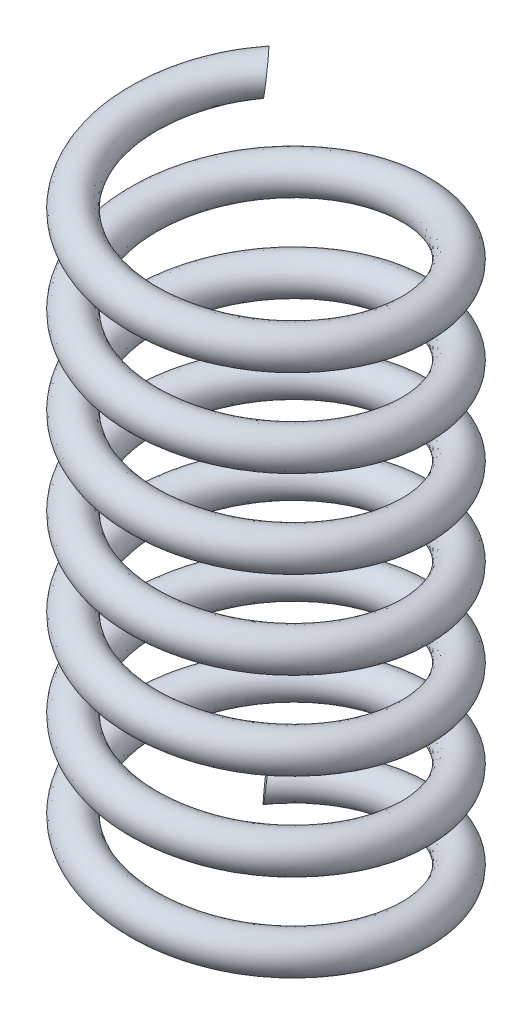
from build123d import *

# Parameters (mm, degrees)
SWEEP1_PITCH       = 1.487714286
SWEEP1_HEIGHT      = 10.414
SWEEP1_RADIUS      = 2.3241
SWEEP1_START_ANGLE = -135
SKETCH2_R          = 0.3175


with BuildPart() as part:
    # Sweep1: sweep along a helix
    with BuildLine() as sweep1_path:
        add(Helix(SWEEP1_PITCH, SWEEP1_HEIGHT, SWEEP1_RADIUS, center=(0, 0, 0), direction=(0, 1, 0), lefthand=True, mode=Mode.PRIVATE).rotate(Axis((0, 0, 0), (0, 1, 0)), SWEEP1_START_ANGLE))
    # Sketch2 → Sweep1 (sweep)
    with BuildSketch(Plane(origin=(-1.64338687, 10.414, -1.64338687), x_dir=(-0.696310209, -0.100078792, -0.710729434), z_dir=(0.703465452, 0.101354404, -0.703465452))):
        with Locations((-4.547345281, -1.219185237)):
            Circle(SKETCH2_R)
    sweep(path=sweep1_path.line, is_frenet=True)


solid = part.part
